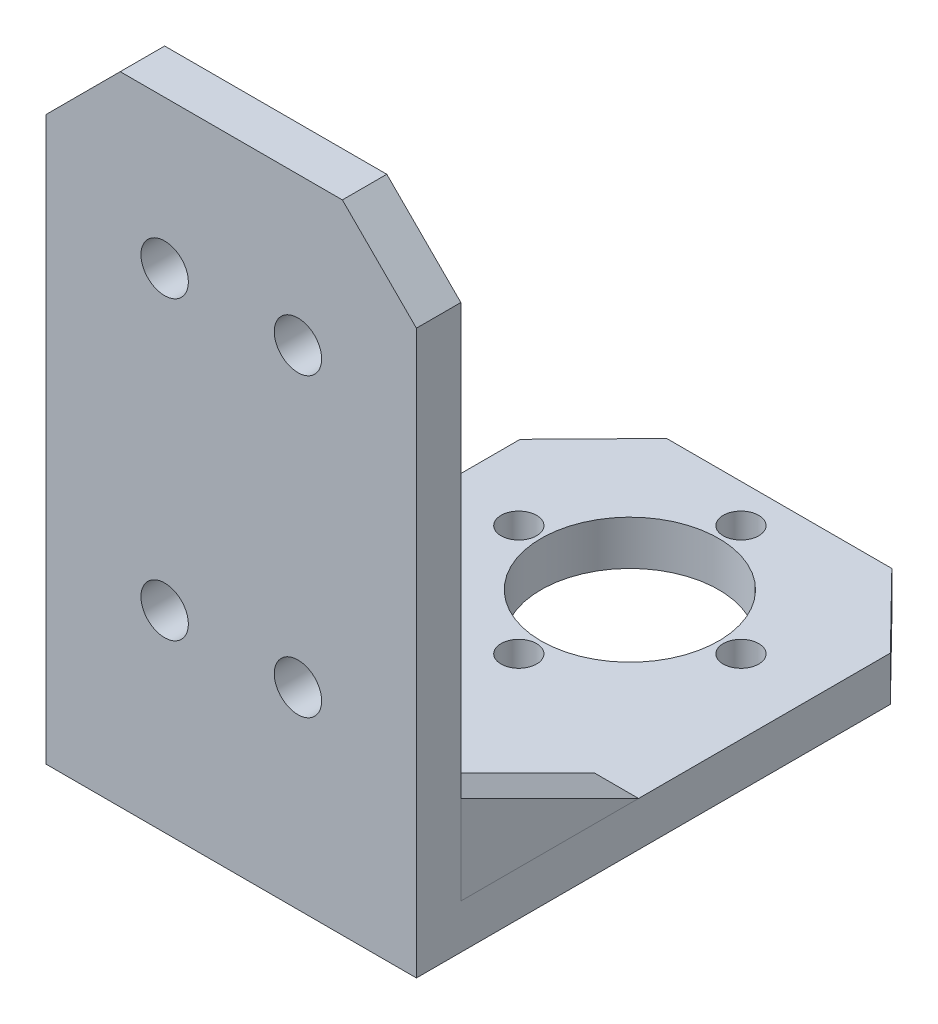
from build123d import *

# Parameters (mm, degrees)
SKETCH2_R                      = 6
SKETCH2_R_2                    = 1.2
BOSS_EXTRUDE1_DEPTH            = 3
SKETCH4_W                      = 25
SKETCH4_H                      = 3
BOSS_EXTRUDE2_DEPTH            = 40
CUT_EXTRUDE1_DEPTH             = 8
F_3_2_3_2_DIAMETER_HOLE1_D     = 3.2
F_3_2_3_2_DIAMETER_HOLE1_DEPTH = 3.2
F_3_2_3_2_DIAMETER_HOLE1_TIP   = 0.96137699
GUSSET1_THICKNESS              = 3
GUSSET2_THICKNESS              = 3


with BuildPart() as part:
    # Sketch2 → Boss-Extrude1 (new body)
    with BuildSketch(Plane(origin=(0, 0, 0), x_dir=(1, 0, 0), z_dir=(0, 1, 0))):
        Polygon((-25.281070854, -53.721991781), (-50.281070854, -53.721991781), (-50.281070854, -21.721991781), (-45.382091368, -16.721991781), (-30.180050339, -16.721991781), (-25.281070854, -21.721991781), align=None)
        with Locations(Location((-37.781070854, -26.807484951, 0), (0, 0, 270))):
            Circle(SKETCH2_R, mode=Mode.SUBTRACT)
        with Locations(Location((-37.781070854, -19.307484951, 0), (0, 0, 270))):
            Circle(SKETCH2_R_2, mode=Mode.SUBTRACT)
        with Locations(Location((-45.281070854, -26.807484951, 0), (0, 0, 270))):
            Circle(SKETCH2_R_2, mode=Mode.SUBTRACT)
        with Locations(Location((-37.781070854, -34.307484951, 0), (0, 0, 270))):
            Circle(SKETCH2_R_2, mode=Mode.SUBTRACT)
        with Locations(Location((-30.281070854, -26.807484951, 0), (0, 0, 270))):
            Circle(SKETCH2_R_2, mode=Mode.SUBTRACT)
    extrude(amount=BOSS_EXTRUDE1_DEPTH)

    # Sketch4 → Boss-Extrude2 (add)
    with BuildSketch(Plane(origin=(0, 3, 0), x_dir=(1, 0, 0), z_dir=(0, 1, 0))):
        with Locations((-37.781070854, -52.221991781)):
            Rectangle(SKETCH4_W, SKETCH4_H)
    extrude(amount=BOSS_EXTRUDE2_DEPTH)

    # Sketch5 → Cut-Extrude1 (cut)
    with BuildSketch(Plane(origin=(0, 0, 50.721991781), x_dir=(-1, 0, 0), z_dir=(0, 0, -1))):
        Polygon((25.281070854, 43), (25.281070854, 38), (30.281070854, 43), align=None)
        Polygon((50.281070854, 43), (45.281070854, 43), (50.281070854, 38), align=None)
    extrude(amount=-CUT_EXTRUDE1_DEPTH, mode=Mode.SUBTRACT)

    # Ø3.2 (3.2) Diameter Hole1
    with Locations(Plane(origin=(0, 0, 50.721991781), x_dir=(-1, 0, 0), z_dir=(0, 0, -1))):
        with Locations((33.281070854, 33), (42.281070854, 33), (42.281070854, 13), (33.281070854, 13)):
            Hole(F_3_2_3_2_DIAMETER_HOLE1_D / 2, depth=F_3_2_3_2_DIAMETER_HOLE1_DEPTH)
            with Locations((0, 0, -(F_3_2_3_2_DIAMETER_HOLE1_DEPTH + F_3_2_3_2_DIAMETER_HOLE1_TIP / 2))):  # 118° drill point
                Cone(0, F_3_2_3_2_DIAMETER_HOLE1_D / 2, F_3_2_3_2_DIAMETER_HOLE1_TIP, mode=Mode.SUBTRACT)


with BuildPart() as body_2:
    # Gusset1: a gusset: a plate 3.0 thick in the corner of two members, its outline drawn in place
    gusset1_outline = Wire([Line((-47.281070854, 3, 50.721991781), (-47.281070854, 3, 38.721991781)), Line((-47.281070854, 3, 38.721991781), (-47.281070854, 9, 50.721991781)), Line((-47.281070854, 9, 50.721991781), (-47.281070854, 3, 50.721991781))])
    add(extrude(Face(gusset1_outline), amount=GUSSET1_THICKNESS, dir=(-1, 0, 0)))


with BuildPart() as body_3:
    # Gusset2: a gusset: a plate 3.0 thick in the corner of two members, its outline drawn in place
    gusset2_outline = Wire([Line((-28.281070854, 3, 50.721991781), (-28.281070854, 9, 50.721991781)), Line((-28.281070854, 9, 50.721991781), (-28.281070854, 3, 38.721991781)), Line((-28.281070854, 3, 38.721991781), (-28.281070854, 3, 50.721991781))])
    add(extrude(Face(gusset2_outline), amount=GUSSET2_THICKNESS, dir=(1, 0, 0)))


solid = Compound([part.part, body_2.part, body_3.part])
